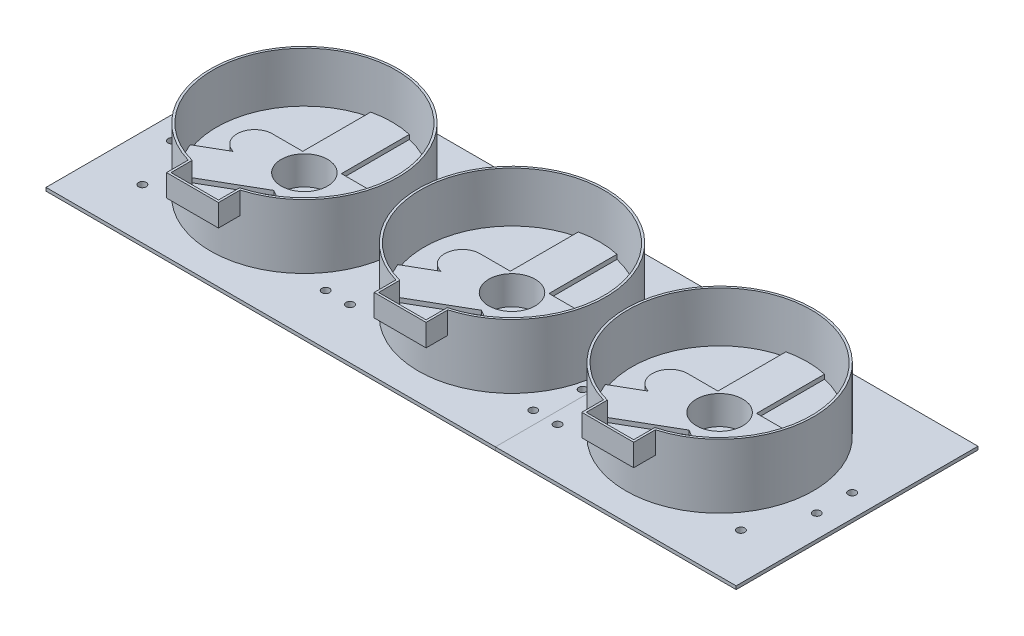
from build123d import *

# Parameters (mm, degrees)
SKETCH1_W               = 303
SKETCH1_H               = 100
BOSS_EXTRUDE1_DEPTH     = 3
SKETCH2_W               = 303
SKETCH2_H               = 100
SKETCH2_W_2             = 299
SKETCH2_H_2             = 96
BOSS_EXTRUDE3_DEPTH     = 1.5
SKETCH3_W               = 100
SKETCH3_H               = 1.5
BOSS_EXTRUDE4_DEPTH     = 4.75
CUT_EXTRUDE2_DEPTH      = 2
CUT_EXTRUDE3_DEPTH      = 4.5
CUT_EXTRUDE3_DEPTH_BACK = 2
SKETCH7_W               = 312.5
SKETCH7_H               = 1.5
BOSS_EXTRUDE5_DEPTH     = 4.75
BOSS_EXTRUDE6_DEPTH     = 2
SKETCH9_R               = 10.5
CUT_EXTRUDE4_DEPTH      = 2
SKETCH11_R              = 6
CUT_EXTRUDE5_DEPTH      = 4.5
CUT_EXTRUDE5_DEPTH_BACK = 2
SKETCH12_W              = 299
SKETCH12_H              = 96
SKETCH12_R              = 10.5
BOSS_EXTRUDE8_DEPTH     = 11
BOSS_EXTRUDE10_DEPTH    = 11
SKETCH18_W              = 299
SKETCH18_H              = 96
CUT_EXTRUDE8_DEPTH      = 9.5
SKETCH20_R              = 42.5
SKETCH20_R_2            = 41.5
EXTRUDE_THIN1_DEPTH     = 19
SKETCH21_R              = 1.75
CUT_EXTRUDE9_DEPTH      = 1
CUT_EXTRUDE9_DEPTH_BACK = 24.5
BOSS_EXTRUDE13_DEPTH    = 10
LPATTERN1_COUNT         = 3
LPATTERN1_PITCH         = 94


with BuildPart() as part:
    # Sketch1 → Boss-Extrude1 (new body)
    with BuildSketch(Plane(origin=(0, 0, 0), x_dir=(1, 0, 0), z_dir=(0, 1, 0))):
        Rectangle(SKETCH1_W, SKETCH1_H)
    extrude(amount=BOSS_EXTRUDE1_DEPTH)

    # Sketch2 → Boss-Extrude3 (add)
    with BuildSketch(Plane(origin=(0, 3, 0), x_dir=(1, 0, 0), z_dir=(0, 1, 0))):
        Rectangle(SKETCH2_W, SKETCH2_H)
        Rectangle(SKETCH2_W_2, SKETCH2_H_2, mode=Mode.SUBTRACT)
    extrude(amount=BOSS_EXTRUDE3_DEPTH)

    # Sketch3 → Boss-Extrude4 (add)
    with BuildSketch(Plane(origin=(151.5, 0, 0), x_dir=(0, 0, -1), z_dir=(1, 0, 0))):
        with Locations((0, 3.75)):
            Rectangle(SKETCH3_W, SKETCH3_H)
    boss_extrude4 = extrude(amount=BOSS_EXTRUDE4_DEPTH)

    # Sketch5 → Cut-Extrude2 (cut)
    with BuildSketch(Plane(origin=(0, 3, 0), x_dir=(1, 0, 0), z_dir=(0, 1, 0))):
        with BuildLine():
            Line((-85.25, 1.294991941), (-57.15793626, -14.923968621))
            ThreePointArc((-57.15793626, -14.923968621), (-54.983756372, -7.602317619), (-54.25, 0))
            ThreePointArc((-54.25, 0), (-62.952657119, 24.821865361), (-85.25, 38.774991941))
            Line((-85.25, 38.774991941), (-85.25, 1.294991941))
        make_face()
        with BuildLine():
            ThreePointArc((-102.75, 38.774991941), (-129.221494295, 18.425765646), (-130.84206374, -14.923968621))
            Line((-130.84206374, -14.923968621), (-102.75, 1.294991941))
            Line((-102.75, 1.294991941), (-102.75, 38.774991941))
        make_face()
        with BuildLine():
            ThreePointArc((-120.815679186, -29.342492222), (-94, -39.75), (-67.184320814, -29.342492222))
            Line((-67.184320814, -29.342492222), (-94, -13.860452626))
            Line((-94, -13.860452626), (-120.815679186, -29.342492222))
        make_face()
        with BuildLine():
            ThreePointArc((-8.75, 38.774991941), (-35.221494295, 18.425765646), (-36.84206374, -14.923968621))
            Line((-36.84206374, -14.923968621), (-8.75, 1.294991941))
            Line((-8.75, 1.294991941), (-8.75, 38.774991941))
        make_face()
        with BuildLine():
            ThreePointArc((-26.815679186, -29.342492222), (0, -39.75), (26.815679186, -29.342492222))
            Line((26.815679186, -29.342492222), (0, -13.860452626))
            Line((0, -13.860452626), (-26.815679186, -29.342492222))
        make_face()
        with BuildLine():
            Line((8.75, 1.294991941), (36.84206374, -14.923968621))
            ThreePointArc((36.84206374, -14.923968621), (39.016243628, -7.602317619), (39.75, 0))
            ThreePointArc((39.75, 0), (31.047342881, 24.821865361), (8.75, 38.774991941))
            Line((8.75, 38.774991941), (8.75, 1.294991941))
        make_face()
        with BuildLine():
            ThreePointArc((133.75, 0), (125.047342881, 24.821865361), (102.75, 38.774991941))
            Line((102.75, 38.774991941), (102.75, 1.294991941))
            Line((102.75, 1.294991941), (130.84206374, -14.923968621))
            ThreePointArc((130.84206374, -14.923968621), (133.016243628, -7.602317619), (133.75, 0))
        make_face()
        with BuildLine():
            ThreePointArc((67.184320814, -29.342492222), (94, -39.75), (120.815679186, -29.342492222))
            Line((120.815679186, -29.342492222), (94, -13.860452626))
            Line((94, -13.860452626), (67.184320814, -29.342492222))
        make_face()
        with BuildLine():
            Line((85.25, 1.294991941), (85.25, 38.774991941))
            ThreePointArc((85.25, 38.774991941), (58.778505705, 18.425765646), (57.15793626, -14.923968621))
            Line((57.15793626, -14.923968621), (85.25, 1.294991941))
        make_face()
    extrude(amount=-CUT_EXTRUDE2_DEPTH, mode=Mode.SUBTRACT)

    # Sketch6 → Cut-Extrude3 (cut, two sides)
    with BuildSketch(Plane(origin=(0, 1, 0), x_dir=(1, 0, 0), z_dir=(0, 1, 0))) as cut_extrude3_sk:
        with BuildLine():
            Line((-6.5, -26.360452626), (6.5, -26.360452626))
            ThreePointArc((6.5, -26.360452626), (7.914213562, -26.946239063), (8.5, -28.360452626))
            Line((8.5, -28.360452626), (8.5, -35.360452626))
            ThreePointArc((8.5, -35.360452626), (7.914213562, -36.774666188), (6.5, -37.360452626))
            Line((6.5, -37.360452626), (-6.5, -37.360452626))
            ThreePointArc((-6.5, -37.360452626), (-7.914213562, -36.774666188), (-8.5, -35.360452626))
            Line((-8.5, -35.360452626), (-8.5, -28.360452626))
            ThreePointArc((-8.5, -28.360452626), (-7.914213562, -26.946239063), (-6.5, -26.360452626))
        make_face()
        with BuildLine():
            Line((-100.5, -26.360452626), (-87.5, -26.360452626))
            ThreePointArc((-87.5, -26.360452626), (-86.085786438, -26.946239063), (-85.5, -28.360452626))
            Line((-85.5, -28.360452626), (-85.5, -35.360452626))
            ThreePointArc((-85.5, -35.360452626), (-86.085786438, -36.774666188), (-87.5, -37.360452626))
            Line((-87.5, -37.360452626), (-100.5, -37.360452626))
            ThreePointArc((-100.5, -37.360452626), (-101.914213562, -36.774666188), (-102.5, -35.360452626))
            Line((-102.5, -35.360452626), (-102.5, -28.360452626))
            ThreePointArc((-102.5, -28.360452626), (-101.914213562, -26.946239063), (-100.5, -26.360452626))
        make_face()
        with BuildLine():
            Line((87.5, -26.360452626), (100.5, -26.360452626))
            ThreePointArc((100.5, -26.360452626), (101.914213562, -26.946239063), (102.5, -28.360452626))
            Line((102.5, -28.360452626), (102.5, -35.360452626))
            ThreePointArc((102.5, -35.360452626), (101.914213562, -36.774666188), (100.5, -37.360452626))
            Line((100.5, -37.360452626), (87.5, -37.360452626))
            ThreePointArc((87.5, -37.360452626), (86.085786438, -36.774666188), (85.5, -35.360452626))
            Line((85.5, -35.360452626), (85.5, -28.360452626))
            ThreePointArc((85.5, -28.360452626), (86.085786438, -26.946239063), (87.5, -26.360452626))
        make_face()
    extrude(amount=CUT_EXTRUDE3_DEPTH, mode=Mode.SUBTRACT)
    extrude(cut_extrude3_sk.sketch, amount=-CUT_EXTRUDE3_DEPTH_BACK, mode=Mode.SUBTRACT)

    # Mirror1: Boss-Extrude4 across plane
    add(boss_extrude4.mirror(Plane(origin=(0, 0, 0), x_dir=(0, 0, 1), z_dir=(1, 0, 0))))

    # Sketch7 → Boss-Extrude5 (add)
    with BuildSketch(Plane.XY.offset(50)):
        with Locations((0, 3.75)):
            Rectangle(SKETCH7_W, SKETCH7_H)
    boss_extrude5 = extrude(amount=BOSS_EXTRUDE5_DEPTH)

    # Mirror2: Boss-Extrude5 across plane
    add(boss_extrude5.mirror(Plane.XY))

    # Sketch8 → Boss-Extrude6 (add)
    with BuildSketch(Plane(origin=(0, 3, 0), x_dir=(1, 0, 0), z_dir=(0, 1, 0))):
        with BuildLine():
            Line((-22.5, 8), (22.5, 8))
            ThreePointArc((22.5, 8), (30.5, 0), (22.5, -8))
            Line((22.5, -8), (-22.5, -8))
            ThreePointArc((-22.5, -8), (-30.5, 0), (-22.5, 8))
        make_face()
        with BuildLine():
            Line((116.5, 8), (71.5, 8))
            ThreePointArc((71.5, 8), (63.5, 0), (71.5, -8))
            Line((71.5, -8), (116.5, -8))
            ThreePointArc((116.5, -8), (124.5, 0), (116.5, 8))
        make_face()
        with BuildLine():
            Line((-71.5, 8), (-116.5, 8))
            ThreePointArc((-116.5, 8), (-124.5, 0), (-116.5, -8))
            Line((-116.5, -8), (-71.5, -8))
            ThreePointArc((-71.5, -8), (-63.5, 0), (-71.5, 8))
        make_face()
    extrude(amount=-BOSS_EXTRUDE6_DEPTH)

    # Sketch9 → Cut-Extrude4 (cut)
    with BuildSketch(Plane(origin=(0, 3, 0), x_dir=(1, 0, 0), z_dir=(0, 1, 0))):
        with Locations(Location((0, 0, 0), (0, 0, 270))):  # turned: the seam where the file's is
            Circle(SKETCH9_R)
        with Locations(Location((94, 0, 0), (0, 0, 270))):  # turned: the seam where the file's is
            Circle(SKETCH9_R)
        with Locations(Location((-94, 0, 0), (0, 0, 270))):  # turned: the seam where the file's is
            Circle(SKETCH9_R)
    extrude(amount=-CUT_EXTRUDE4_DEPTH, mode=Mode.SUBTRACT)

    # Sketch11 → Cut-Extrude5 (cut, two sides)
    with BuildSketch(Plane(origin=(0, 1, 0), x_dir=(1, 0, 0), z_dir=(0, 1, 0))) as cut_extrude5_sk:
        with Locations(Location((0, 0, 0), (0, 0, 270))):  # turned: the seam where the file's is
            Circle(SKETCH11_R)
        with Locations(Location((94, 0, 0), (0, 0, 270))):  # turned: the seam where the file's is
            Circle(SKETCH11_R)
        with Locations(Location((-94, 0, 0), (0, 0, 270))):  # turned: the seam where the file's is
            Circle(SKETCH11_R)
    extrude(amount=CUT_EXTRUDE5_DEPTH, mode=Mode.SUBTRACT)
    extrude(cut_extrude5_sk.sketch, amount=-CUT_EXTRUDE5_DEPTH_BACK, mode=Mode.SUBTRACT)

    # Sketch12 → Boss-Extrude8 (add)
    with BuildSketch(Plane(origin=(0, 3, 0), x_dir=(1, 0, 0), z_dir=(0, 1, 0))):
        Rectangle(SKETCH12_W, SKETCH12_H)
        with Locations(Location((94, 0, 0), (0, 0, 270))):  # turned: the seam where the file's is
            Circle(SKETCH12_R, mode=Mode.SUBTRACT)
        with Locations(Location((0, 0, 0), (0, 0, 270))):  # turned: the seam where the file's is
            Circle(SKETCH12_R, mode=Mode.SUBTRACT)
        with Locations(Location((-94, 0, 0), (0, 0, 270))):  # turned: the seam where the file's is
            Circle(SKETCH12_R, mode=Mode.SUBTRACT)
        with BuildLine():
            Line((116.5, 8), (102.75, 8))
            Line((102.75, 8), (102.75, 38.774991941))
            ThreePointArc((102.75, 38.774991941), (129.221494295, 18.425765646), (130.84206374, -14.923968621))
            Line((130.84206374, -14.923968621), (118.437071085, -7.761942773))
            ThreePointArc((118.437071085, -7.761942773), (124.440262659, 0.97582217), (116.5, 8))
        make_face(mode=Mode.SUBTRACT)
        with BuildLine():
            Line((67.184320814, -29.342492222), (94, -13.860452626))
            Line((94, -13.860452626), (120.815679186, -29.342492222))
            ThreePointArc((120.815679186, -29.342492222), (94, -39.75), (67.184320814, -29.342492222))
        make_face(mode=Mode.SUBTRACT)
        with BuildLine():
            Line((85.25, 38.774991941), (85.25, 8))
            Line((85.25, 8), (71.5, 8))
            ThreePointArc((71.5, 8), (63.559737341, 0.97582217), (69.562928915, -7.761942773))
            Line((69.562928915, -7.761942773), (57.15793626, -14.923968621))
            ThreePointArc((57.15793626, -14.923968621), (58.778505705, 18.425765646), (85.25, 38.774991941))
        make_face(mode=Mode.SUBTRACT)
        with BuildLine():
            Line((36.84206374, -14.923968621), (24.437071085, -7.761942773))
            ThreePointArc((24.437071085, -7.761942773), (30.440262659, 0.97582217), (22.5, 8))
            Line((22.5, 8), (8.75, 8))
            Line((8.75, 8), (8.75, 38.774991941))
            ThreePointArc((8.75, 38.774991941), (35.221494295, 18.425765646), (36.84206374, -14.923968621))
        make_face(mode=Mode.SUBTRACT)
        with BuildLine():
            Line((-26.815679186, -29.342492222), (0, -13.860452626))
            Line((0, -13.860452626), (26.815679186, -29.342492222))
            ThreePointArc((26.815679186, -29.342492222), (0, -39.75), (-26.815679186, -29.342492222))
        make_face(mode=Mode.SUBTRACT)
        with BuildLine():
            Line((-36.84206374, -14.923968621), (-24.437071085, -7.761942773))
            ThreePointArc((-24.437071085, -7.761942773), (-30.440262659, 0.97582217), (-22.5, 8))
            Line((-22.5, 8), (-8.75, 8))
            Line((-8.75, 8), (-8.75, 38.774991941))
            ThreePointArc((-8.75, 38.774991941), (-35.221494295, 18.425765646), (-36.84206374, -14.923968621))
        make_face(mode=Mode.SUBTRACT)
        with BuildLine():
            Line((-57.15793626, -14.923968621), (-69.562928915, -7.761942773))
            ThreePointArc((-69.562928915, -7.761942773), (-63.559737341, 0.97582217), (-71.5, 8))
            Line((-71.5, 8), (-85.25, 8))
            Line((-85.25, 8), (-85.25, 38.774991941))
            ThreePointArc((-85.25, 38.774991941), (-58.778505705, 18.425765646), (-57.15793626, -14.923968621))
        make_face(mode=Mode.SUBTRACT)
        with BuildLine():
            Line((-120.815679186, -29.342492222), (-94, -13.860452626))
            Line((-94, -13.860452626), (-67.184320814, -29.342492222))
            ThreePointArc((-67.184320814, -29.342492222), (-94, -39.75), (-120.815679186, -29.342492222))
        make_face(mode=Mode.SUBTRACT)
        with BuildLine():
            Line((-130.84206374, -14.923968621), (-118.437071085, -7.761942773))
            ThreePointArc((-118.437071085, -7.761942773), (-124.440262659, 0.97582217), (-116.5, 8))
            Line((-116.5, 8), (-102.75, 8))
            Line((-102.75, 8), (-102.75, 38.774991941))
            ThreePointArc((-102.75, 38.774991941), (-129.221494295, 18.425765646), (-130.84206374, -14.923968621))
        make_face(mode=Mode.SUBTRACT)
    extrude(amount=BOSS_EXTRUDE8_DEPTH)

    # Sketch13 → Boss-Extrude10 (add)
    with BuildSketch(Plane(origin=(0, 1, 0), x_dir=(1, 0, 0), z_dir=(0, 1, 0))):
        with BuildLine():
            Line((120.815679186, -29.342492222), (94, -13.860452626))
            Line((94, -13.860452626), (67.184320814, -29.342492222))
            ThreePointArc((67.184320814, -29.342492222), (94, -39.75), (120.815679186, -29.342492222))
        make_face()
        with BuildLine():
            Line((87.5, -37.360452626), (100.5, -37.360452626))
            ThreePointArc((100.5, -37.360452626), (101.914213562, -36.774666188), (102.5, -35.360452626))
            Line((102.5, -35.360452626), (102.5, -28.360452626))
            ThreePointArc((102.5, -28.360452626), (101.914213562, -26.946239063), (100.5, -26.360452626))
            Line((100.5, -26.360452626), (87.5, -26.360452626))
            ThreePointArc((87.5, -26.360452626), (86.085786438, -26.946239063), (85.5, -28.360452626))
            Line((85.5, -28.360452626), (85.5, -35.360452626))
            ThreePointArc((85.5, -35.360452626), (86.085786438, -36.774666188), (87.5, -37.360452626))
        make_face(mode=Mode.SUBTRACT)
        with BuildLine():
            Line((26.815679186, -29.342492222), (0, -13.860452626))
            Line((0, -13.860452626), (-26.815679186, -29.342492222))
            ThreePointArc((-26.815679186, -29.342492222), (0, -39.75), (26.815679186, -29.342492222))
        make_face()
        with BuildLine():
            Line((-6.5, -37.360452626), (6.5, -37.360452626))
            ThreePointArc((6.5, -37.360452626), (7.914213562, -36.774666188), (8.5, -35.360452626))
            Line((8.5, -35.360452626), (8.5, -28.360452626))
            ThreePointArc((8.5, -28.360452626), (7.914213562, -26.946239063), (6.5, -26.360452626))
            Line((6.5, -26.360452626), (-6.5, -26.360452626))
            ThreePointArc((-6.5, -26.360452626), (-7.914213562, -26.946239063), (-8.5, -28.360452626))
            Line((-8.5, -28.360452626), (-8.5, -35.360452626))
            ThreePointArc((-8.5, -35.360452626), (-7.914213562, -36.774666188), (-6.5, -37.360452626))
        make_face(mode=Mode.SUBTRACT)
        with BuildLine():
            Line((-120.815679186, -29.342492222), (-94, -13.860452626))
            Line((-94, -13.860452626), (-67.184320814, -29.342492222))
            ThreePointArc((-67.184320814, -29.342492222), (-94, -39.75), (-120.815679186, -29.342492222))
        make_face()
        with BuildLine():
            Line((-85.5, -35.360452626), (-85.5, -28.360452626))
            ThreePointArc((-85.5, -28.360452626), (-86.085786438, -26.946239063), (-87.5, -26.360452626))
            Line((-87.5, -26.360452626), (-100.5, -26.360452626))
            ThreePointArc((-100.5, -26.360452626), (-101.914213562, -26.946239063), (-102.5, -28.360452626))
            Line((-102.5, -28.360452626), (-102.5, -35.360452626))
            ThreePointArc((-102.5, -35.360452626), (-101.914213562, -36.774666188), (-100.5, -37.360452626))
            Line((-100.5, -37.360452626), (-87.5, -37.360452626))
            ThreePointArc((-87.5, -37.360452626), (-86.085786438, -36.774666188), (-85.5, -35.360452626))
        make_face(mode=Mode.SUBTRACT)
        with BuildLine():
            Line((118.437071085, -7.761942773), (130.84206374, -14.923968621))
            ThreePointArc((130.84206374, -14.923968621), (129.221494295, 18.425765646), (102.75, 38.774991941))
            Line((102.75, 38.774991941), (102.75, 8))
            Line((102.75, 8), (116.5, 8))
            ThreePointArc((116.5, 8), (124.440262659, 0.97582217), (118.437071085, -7.761942773))
        make_face()
        with BuildLine():
            Line((71.5, 8), (85.25, 8))
            Line((85.25, 8), (85.25, 38.774991941))
            ThreePointArc((85.25, 38.774991941), (58.778505705, 18.425765646), (57.15793626, -14.923968621))
            Line((57.15793626, -14.923968621), (69.562928915, -7.761942773))
            ThreePointArc((69.562928915, -7.761942773), (63.559737341, 0.97582217), (71.5, 8))
        make_face()
        with BuildLine():
            Line((8.75, 8), (22.5, 8))
            ThreePointArc((22.5, 8), (30.440262659, 0.97582217), (24.437071085, -7.761942773))
            Line((24.437071085, -7.761942773), (36.84206374, -14.923968621))
            ThreePointArc((36.84206374, -14.923968621), (35.221494295, 18.425765646), (8.75, 38.774991941))
            Line((8.75, 38.774991941), (8.75, 8))
        make_face()
        with BuildLine():
            Line((-22.5, 8), (-8.75, 8))
            Line((-8.75, 8), (-8.75, 38.774991941))
            ThreePointArc((-8.75, 38.774991941), (-35.221494295, 18.425765646), (-36.84206374, -14.923968621))
            Line((-36.84206374, -14.923968621), (-24.437071085, -7.761942773))
            ThreePointArc((-24.437071085, -7.761942773), (-30.440262659, 0.97582217), (-22.5, 8))
        make_face()
        with BuildLine():
            Line((-116.5, 8), (-102.75, 8))
            Line((-102.75, 8), (-102.75, 38.774991941))
            ThreePointArc((-102.75, 38.774991941), (-129.221494295, 18.425765646), (-130.84206374, -14.923968621))
            Line((-130.84206374, -14.923968621), (-118.437071085, -7.761942773))
            ThreePointArc((-118.437071085, -7.761942773), (-124.440262659, 0.97582217), (-116.5, 8))
        make_face()
        with BuildLine():
            Line((-69.562928915, -7.761942773), (-57.15793626, -14.923968621))
            ThreePointArc((-57.15793626, -14.923968621), (-58.778505705, 18.425765646), (-85.25, 38.774991941))
            Line((-85.25, 38.774991941), (-85.25, 8))
            Line((-85.25, 8), (-71.5, 8))
            ThreePointArc((-71.5, 8), (-63.559737341, 0.97582217), (-69.562928915, -7.761942773))
        make_face()
    extrude(amount=BOSS_EXTRUDE10_DEPTH)

    # Sketch18 → Cut-Extrude8 (cut)
    with BuildSketch(Plane(origin=(0, 14, 0), x_dir=(1, 0, 0), z_dir=(0, 1, 0))):
        Rectangle(SKETCH18_W, SKETCH18_H)
        with BuildLine():
            ThreePointArc((-8.75, 38.774991941), (0, 39.75), (8.75, 38.774991941))
            ThreePointArc((8.75, 38.774991941), (35.221494295, 18.425765646), (36.84206374, -14.923968621))
            ThreePointArc((36.84206374, -14.923968621), (32.635111679, -22.693875511), (26.815679186, -29.342492222))
            ThreePointArc((26.815679186, -29.342492222), (0, -39.75), (-26.815679186, -29.342492222))
            ThreePointArc((-26.815679186, -29.342492222), (-32.635111679, -22.693875511), (-36.84206374, -14.923968621))
            ThreePointArc((-36.84206374, -14.923968621), (-35.221494295, 18.425765646), (-8.75, 38.774991941))
        make_face(mode=Mode.SUBTRACT)
        with BuildLine():
            ThreePointArc((-102.75, 38.774991941), (-94, 39.75), (-85.25, 38.774991941))
            ThreePointArc((-85.25, 38.774991941), (-58.778505705, 18.425765646), (-57.15793626, -14.923968621))
            ThreePointArc((-57.15793626, -14.923968621), (-61.364888321, -22.693875511), (-67.184320814, -29.342492222))
            ThreePointArc((-67.184320814, -29.342492222), (-94, -39.75), (-120.815679186, -29.342492222))
            ThreePointArc((-120.815679186, -29.342492222), (-126.635111679, -22.693875511), (-130.84206374, -14.923968621))
            ThreePointArc((-130.84206374, -14.923968621), (-129.221494295, 18.425765646), (-102.75, 38.774991941))
        make_face(mode=Mode.SUBTRACT)
        with BuildLine():
            ThreePointArc((130.84206374, -14.923968621), (126.635111679, -22.693875511), (120.815679186, -29.342492222))
            ThreePointArc((120.815679186, -29.342492222), (94, -39.75), (67.184320814, -29.342492222))
            ThreePointArc((67.184320814, -29.342492222), (61.364888321, -22.693875511), (57.15793626, -14.923968621))
            ThreePointArc((57.15793626, -14.923968621), (58.778505705, 18.425765646), (85.25, 38.774991941))
            ThreePointArc((85.25, 38.774991941), (94, 39.75), (102.75, 38.774991941))
            ThreePointArc((102.75, 38.774991941), (129.221494295, 18.425765646), (130.84206374, -14.923968621))
        make_face(mode=Mode.SUBTRACT)
    extrude(amount=-CUT_EXTRUDE8_DEPTH, mode=Mode.SUBTRACT)

    # Sketch20 → Extrude-Thin1 (add)
    with BuildSketch(Plane(origin=(0, 4.5, 0), x_dir=(1, 0, 0), z_dir=(0, 1, 0))):
        with Locations((94, 0)):
            Circle(SKETCH20_R)
        with Locations((94, 0)):
            Circle(SKETCH20_R_2, mode=Mode.SUBTRACT)
        Circle(SKETCH20_R)
        Circle(SKETCH20_R_2, mode=Mode.SUBTRACT)
        with Locations((-94, 0)):
            Circle(SKETCH20_R)
        with Locations((-94, 0)):
            Circle(SKETCH20_R_2, mode=Mode.SUBTRACT)
    extrude(amount=EXTRUDE_THIN1_DEPTH)

    # Sketch21 → Cut-Extrude9 (cut, two sides)
    with BuildSketch(Plane.XZ) as cut_extrude9_sk:
        with Locations(Location((41.5, 31.860452626, 0), (0, 0, 270))):  # turned: the seam where the file's is
            Circle(SKETCH21_R)
        with Locations(Location((-41.5, 31.860452626, 0), (0, 0, 270))):  # turned: the seam where the file's is
            Circle(SKETCH21_R)
        with Locations(Location((135.5, 31.860452626, 0), (0, 0, 270))):  # turned: the seam where the file's is
            Circle(SKETCH21_R)
        with Locations(Location((52.5, 31.860452626, 0), (0, 0, 270))):  # turned: the seam where the file's is
            Circle(SKETCH21_R)
        with Locations(Location((-135.5, 31.860452626, 0), (0, 0, 270))):  # turned: the seam where the file's is
            Circle(SKETCH21_R)
        with Locations(Location((-52.5, 31.860452626, 0), (0, 0, 270))):  # turned: the seam where the file's is
            Circle(SKETCH21_R)
        with Locations(Location((-146, -8, 0), (0, 0, 270))):  # turned: the seam where the file's is
            Circle(SKETCH21_R)
        with Locations(Location((146, -8, 0), (0, 0, 270))):  # turned: the seam where the file's is
            Circle(SKETCH21_R)
        with Locations(Location((146, 8, 0), (0, 0, 270))):  # turned: the seam where the file's is
            Circle(SKETCH21_R)
        with Locations(Location((-146, 8, 0), (0, 0, 90))):  # turned: the seam where the file's is
            Circle(SKETCH21_R)
        with Locations(Location((44.5, -12.5, 0), (0, 0, 270))):  # turned: the seam where the file's is
            Circle(SKETCH21_R)
        with Locations(Location((44.5, 12.5, 0), (0, 0, 270))):  # turned: the seam where the file's is
            Circle(SKETCH21_R)
    extrude(amount=CUT_EXTRUDE9_DEPTH, mode=Mode.SUBTRACT)
    extrude(cut_extrude9_sk.sketch, amount=-CUT_EXTRUDE9_DEPTH_BACK, mode=Mode.SUBTRACT)

    # Sketch23 → Boss-Extrude13 (add)
    with BuildSketch(Plane(origin=(0, 23.5, 0), x_dir=(1, 0, 0), z_dir=(0, 1, 0))):
        with BuildLine():
            Line((-83.25, -40.083506583), (-83.25, -41.117970524))
            ThreePointArc((-83.25, -41.117970524), (-82.749162688, -40.983760928), (-82.25, -40.843451127))
            ThreePointArc((-82.25, -40.843451127), (-60.046907357, -25.562423594), (-51.5, 0))
            ThreePointArc((-51.5, 0), (-119.562423594, 33.953092643), (-105.75, -40.843451127))
            ThreePointArc((-105.75, -40.843451127), (-105.250837312, -40.983760928), (-104.75, -41.117970524))
            Line((-104.75, -41.117970524), (-104.75, -40.083506583))
            ThreePointArc((-104.75, -40.083506583), (-119.25989905, 32.927002597), (-52.5, 0))
            ThreePointArc((-52.5, 0), (-61.072997403, -25.25989905), (-83.25, -40.083506583))
        make_face()
        with BuildLine():
            ThreePointArc((-82.25, -40.843451127), (-82.749162688, -40.983760928), (-83.25, -41.117970524))
            Line((-83.25, -41.117970524), (-83.25, -49.657970524))
            Line((-83.25, -49.657970524), (-104.75, -49.657970524))
            Line((-104.75, -49.657970524), (-104.75, -41.117970524))
            ThreePointArc((-104.75, -41.117970524), (-105.250837312, -40.983760928), (-105.75, -40.843451127))
            Line((-105.75, -40.843451127), (-105.75, -41.117970524))
            Line((-105.75, -41.117970524), (-105.75, -50.657970524))
            Line((-105.75, -50.657970524), (-82.25, -50.657970524))
            Line((-82.25, -50.657970524), (-82.25, -41.117970524))
            Line((-82.25, -41.117970524), (-82.25, -40.843451127))
        make_face()
    boss_extrude13 = extrude(amount=BOSS_EXTRUDE13_DEPTH)

    # LPattern1: Boss-Extrude13 ×3
    with Locations(*[(i * LPATTERN1_PITCH, 0, 0) for i in range(1, LPATTERN1_COUNT)]):
        add(boss_extrude13)


with BuildPart() as body_2:
    # Split1: the piece on the far side of the plane
    add(part.part)
    split(bisect_by=Plane(origin=(47.25, 0, 0), x_dir=(0, 0, 1), z_dir=(1, 0, 0)), keep=Keep.BOTTOM)


with BuildPart() as part_1:
    add(part.part)

    # Split1
    split(bisect_by=Plane(origin=(47.25, 0, 0), x_dir=(0, 0, 1), z_dir=(1, 0, 0)), keep=Keep.TOP)


solid = Compound([body_2.part, part_1.part])
